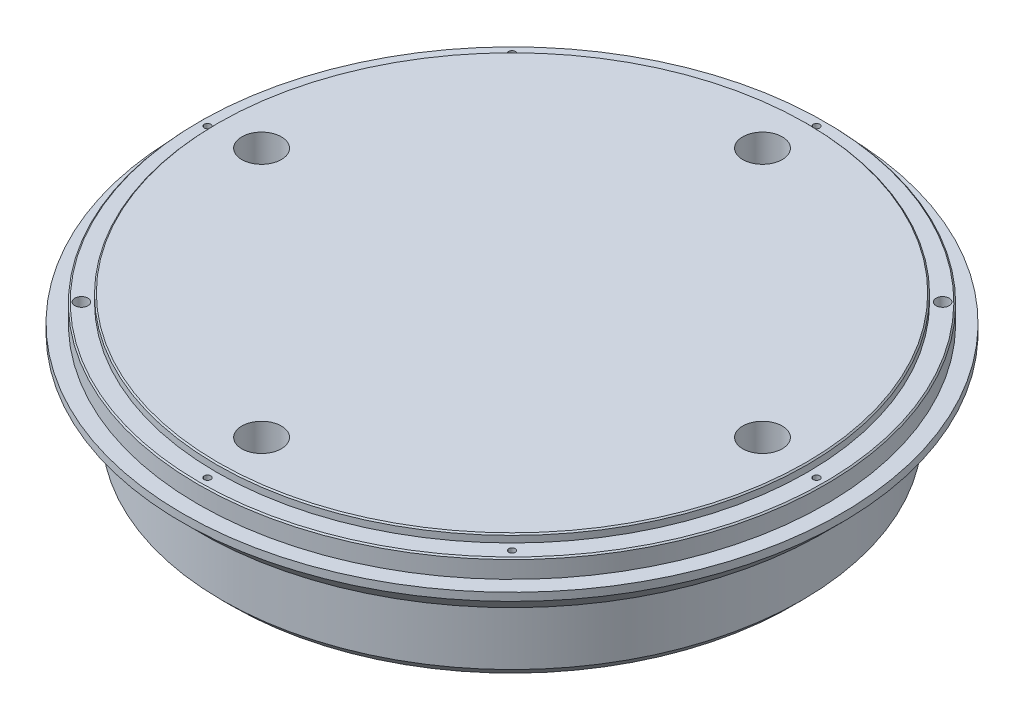
from build123d import *

# Parameters (mm, degrees)
SKETCH1_R                                           = 125
BOSS_EXTRUDE1_DEPTH                                 = 50
SKETCH2_R                                           = 127
SKETCH2_R_2                                         = 119
PAKNING_DEPTH                                       = 10
SKETCH3_R                                           = 125
SKETCH3_R_2                                         = 112
PAKNINGSRING_DEPTH                                  = 3
SKETCH5_R                                           = 5
VARMELEMENT_DEPTH                                   = 45
VARMEELEMENT_PATTERN_COUNT                          = 4
SKETCH6_R                                           = 1.5
CUT_EXTRUDE5_DEPTH                                  = 47
SKETCH7_R                                           = 135
SKETCH7_R_2                                         = 110
CUT_EXTRUDE6_DEPTH                                  = 30
CHAMFER1_SIZE                                       = 7
CHAMFER2_SIZE                                       = 0.5
M12_TAPPED_HOLE1_D                                  = 10.2
M12_TAPPED_HOLE1_DEPTH                              = 20.25
M12_TAPPED_HOLE1_TIP                                = 3.064389157
SKETCH13_R                                          = 8
CUT_EXTRUDE8_DEPTH                                  = 20
CBORE_FOR_M8_HEX_SOCKET_HEAD_CAP_SCREW1_D           = 9
CBORE_FOR_M8_HEX_SOCKET_HEAD_CAP_SCREW1_CBORE_D     = 15
CBORE_FOR_M8_HEX_SOCKET_HEAD_CAP_SCREW1_CBORE_DEPTH = 10.6
CIRPATTERN1_COUNT                                   = 4
CHAMFER3_SIZE                                       = 4
CIRPATTERN2_COUNT                                   = 8
SKETCH18_R                                          = 2.5
CUT_EXTRUDE9_DEPTH                                  = 10
CIRPATTERN3_COUNT                                   = 2


with BuildPart() as part:
    # Sketch1 → Boss-Extrude1 (new body)
    with BuildSketch(Plane(origin=(0, 0, 0), x_dir=(1, 0, 0), z_dir=(0, 1, 0))):
        Circle(SKETCH1_R)
    extrude(amount=BOSS_EXTRUDE1_DEPTH)

    # Sketch2 → Pakning (cut)
    with BuildSketch(Plane(origin=(0, 50, 0), x_dir=(1, 0, 0), z_dir=(0, 1, 0))):
        Circle(SKETCH2_R)
        Circle(SKETCH2_R_2, mode=Mode.SUBTRACT)
    extrude(amount=-PAKNING_DEPTH, mode=Mode.SUBTRACT)

    # Sketch3 → PakningsRing (cut)
    with BuildSketch(Plane(origin=(0, 50, 0), x_dir=(1, 0, 0), z_dir=(0, 1, 0))):
        Circle(SKETCH3_R)
        Circle(SKETCH3_R_2, mode=Mode.SUBTRACT)
    extrude(amount=-PAKNINGSRING_DEPTH, mode=Mode.SUBTRACT)

    # Sketch5 → Varmelement (cut)
    with BuildSketch(Plane(origin=(0, 0, 0), x_dir=(-1, 0, 0), z_dir=(0, -1, 0))):
        with Locations((-42.426406871, 42.426406871)):
            Circle(SKETCH5_R)
    varmelement = extrude(amount=-VARMELEMENT_DEPTH, mode=Mode.SUBTRACT)

    # Varmeelement_pattern: Varmelement ×4 about axis
    varmeelement_pattern_axis = Axis((0, 0, 0), (0, 1, 0))
    for i in range(1, VARMEELEMENT_PATTERN_COUNT):
        add(varmelement.rotate(varmeelement_pattern_axis, i * 360 / VARMEELEMENT_PATTERN_COUNT), mode=Mode.SUBTRACT)

    # Sketch6 → Cut-Extrude5 (cut)
    with BuildSketch(Plane.XZ):
        with Locations((14.142135624, 14.142135624)):
            Circle(SKETCH6_R)
    extrude(amount=-CUT_EXTRUDE5_DEPTH, mode=Mode.SUBTRACT)

    # Sketch7 → Cut-Extrude6 (cut)
    with BuildSketch(Plane.XZ):
        Circle(SKETCH7_R)
        Circle(SKETCH7_R_2, mode=Mode.SUBTRACT)
    extrude(amount=-CUT_EXTRUDE6_DEPTH, mode=Mode.SUBTRACT)

    # Chamfer1
    chamfer1_edges = [part.edges().sort_by_distance(p)[0] for p in [
        (-125, 30, 0),
    ]]
    chamfer(chamfer1_edges, length=CHAMFER1_SIZE)

    # Chamfer2
    chamfer2_edges = [part.edges().sort_by_distance(p)[0] for p in [
        (-119, 47, 0),
        (-112, 50, 0),
    ]]
    chamfer(chamfer2_edges, length=CHAMFER2_SIZE)

    # M12 Tapped Hole1
    with Locations(Plane(origin=(0, 0, 0), x_dir=(-1, 0, 0), z_dir=(0, -1, 0))):
        with Locations((0, 0)):
            Hole(M12_TAPPED_HOLE1_D / 2, depth=M12_TAPPED_HOLE1_DEPTH)
            with Locations((0, 0, -(M12_TAPPED_HOLE1_DEPTH + M12_TAPPED_HOLE1_TIP / 2))):  # 118° drill point
                Cone(0, M12_TAPPED_HOLE1_D / 2, M12_TAPPED_HOLE1_TIP, mode=Mode.SUBTRACT)

    # Sketch13 → Cut-Extrude8 (cut)
    with BuildSketch(Plane(origin=(0, 0, 0), x_dir=(-1, 0, 0), z_dir=(0, -1, 0))):
        with Locations((0, 95)):
            Circle(SKETCH13_R)
    cut_extrude8 = extrude(amount=-CUT_EXTRUDE8_DEPTH, mode=Mode.SUBTRACT)

    # CBORE for M8 Hex Socket Head Cap Screw1 (through all)
    with Locations(Plane(origin=(0, 50, 0), x_dir=(1, 0, 0), z_dir=(0, 1, 0))):
        with Locations((0, 95)):
            cbore_for_m8_hex_socket_head_cap_screw1 = CounterBoreHole(CBORE_FOR_M8_HEX_SOCKET_HEAD_CAP_SCREW1_D / 2, CBORE_FOR_M8_HEX_SOCKET_HEAD_CAP_SCREW1_CBORE_D / 2, CBORE_FOR_M8_HEX_SOCKET_HEAD_CAP_SCREW1_CBORE_DEPTH)

    # CirPattern1: Cut-Extrude8, CBORE for M8 Hex Socket Head Cap Screw1 ×4 about axis
    cirpattern1_axis = Axis((0, 0, 0), (0, 1, 0))
    for i in range(1, CIRPATTERN1_COUNT):
        add(cut_extrude8.rotate(cirpattern1_axis, i * 360 / CIRPATTERN1_COUNT), mode=Mode.SUBTRACT)
        add(cbore_for_m8_hex_socket_head_cap_screw1.rotate(cirpattern1_axis, i * 360 / CIRPATTERN1_COUNT), mode=Mode.SUBTRACT)

    # Chamfer3
    chamfer3_edges = [part.edges().sort_by_distance(p)[0] for p in [
        (-110, 0, 0),
    ]]
    chamfer(chamfer3_edges, length=CHAMFER3_SIZE)

    # Sketch17 → M3 Tapped Hole1 (revolve, cut)
    with BuildSketch(Plane(origin=(0, 47, -115.5), x_dir=(0, 0, 1), z_dir=(1, 0, 0))):
        Polygon((0, 0), (0, 8.251075774), (1.25, 7.5), (1.25, 0), align=None)
    m3_tapped_hole1 = revolve(axis=Axis((0, 53.35, -115.5), (0, -1, 0)), mode=Mode.SUBTRACT)

    # CirPattern2: M3 Tapped Hole1 ×8 about axis, 2 skipped
    cirpattern2_axis = Axis((0, 0, 0), (0, 1, 0))
    add([m3_tapped_hole1.rotate(cirpattern2_axis, i * 360 / CIRPATTERN2_COUNT) for i in range(1, CIRPATTERN2_COUNT) if i not in (3, 7)], mode=Mode.SUBTRACT)

    # Sketch18 → Cut-Extrude9 (cut)
    with BuildSketch(Plane(origin=(0, 47, 0), x_dir=(1, 0, 0), z_dir=(0, 1, 0))):
        with Locations((81.670833227, 81.670833227)):
            Circle(SKETCH18_R)
    cut_extrude9 = extrude(amount=-CUT_EXTRUDE9_DEPTH, mode=Mode.SUBTRACT)

    # CirPattern3: Cut-Extrude9 ×2 about axis
    cirpattern3_axis = Axis((0, 0, 0), (0, 1, 0))
    for i in range(1, CIRPATTERN3_COUNT):
        add(cut_extrude9.rotate(cirpattern3_axis, i * 360 / CIRPATTERN3_COUNT), mode=Mode.SUBTRACT)


solid = part.part
